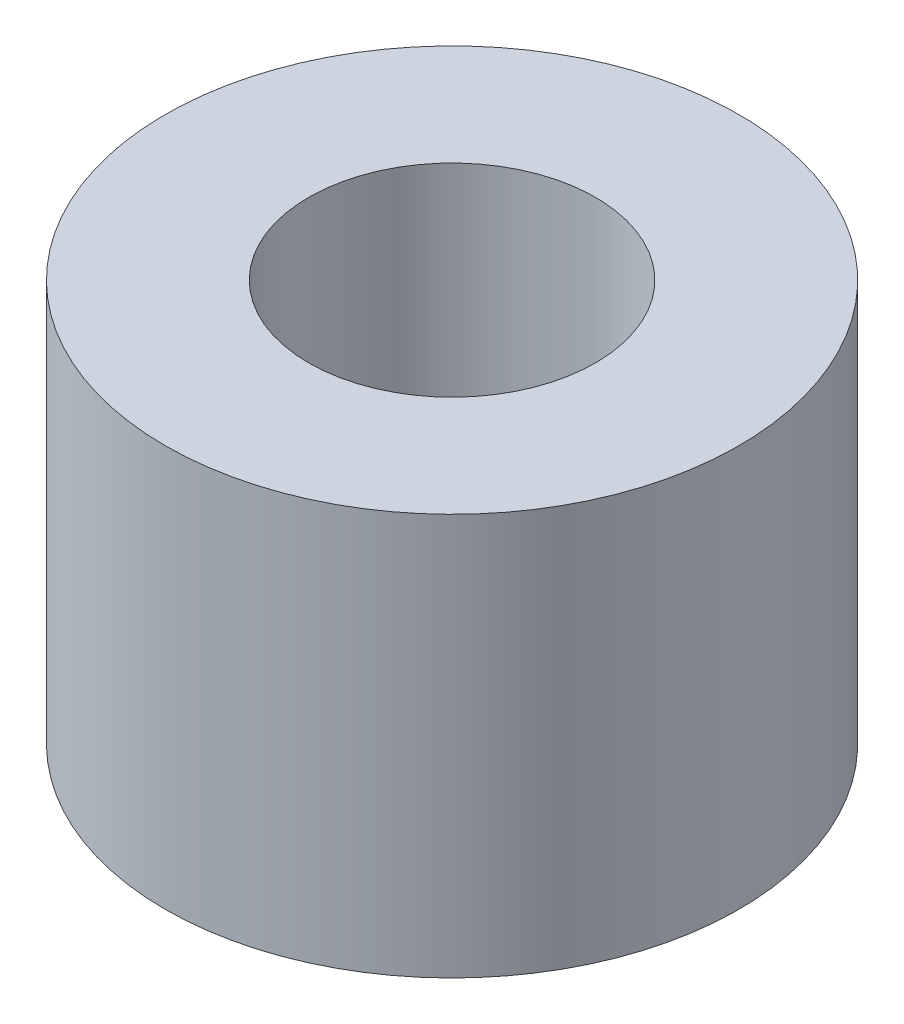
from build123d import *

# Parameters (mm, degrees)
SKETCH9_R           = 4
SKETCH9_R_2         = 2
BOSS_EXTRUDE6_DEPTH = 5.6


with BuildPart() as part:
    # Sketch9 → Boss-Extrude6 (new body)
    with BuildSketch(Plane(origin=(0, 0, 0), x_dir=(1, 0, 0), z_dir=(0, 1, 0))):
        Circle(SKETCH9_R)
        Circle(SKETCH9_R_2, mode=Mode.SUBTRACT)
    extrude(amount=BOSS_EXTRUDE6_DEPTH)


solid = part.part
